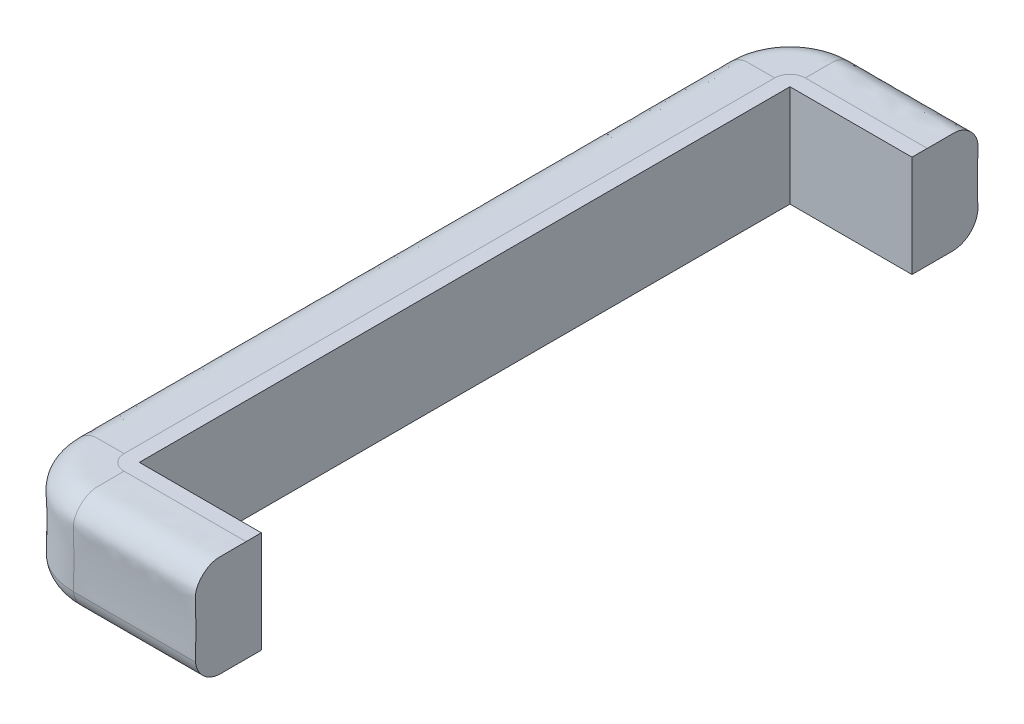
from build123d import *

# Parameters (mm, degrees)
BOSS_EXTRUDE1_DEPTH = 812.8
REVOLVE1_ANGLE      = 90
REVOLVE2_ANGLE      = 90
BOSS_EXTRUDE2_DEPTH = 152.4


with BuildPart() as part:
    # Sketch1 → Boss-Extrude1 (new body)
    with BuildSketch(Plane.XY):
        with BuildLine():
            ThreePointArc((-82.355538681, 28.241370844), (-71.973846397, 8.091370945), (-50.800000578, 0))
            ThreePointArc((-50.800000578, 0), (-28.349359902, 9.299359493), (-19.05, 31.75))
            ThreePointArc((-19.05, 31.75), (-28.349359697, 54.200640303), (-50.8, 63.5))
            ThreePointArc((-50.8, 63.5), (-71.17526234, 56.09976765), (-82.052466379, 37.348736037))
            add(Edge.make_bspline(
                [(-82.052466379, 37.348736037), (-82.090976805, 36.231888795), (-82.212926403, 33.023152502), (-82.359373775, 30.100112808), (-82.355538681, 28.241370844)],
                knots=[0.598459565, 0.598459565, 0.598459565, 0.598459565, 0.612182288, 0.638921764, 0.638921764, 0.638921764, 0.638921764], degree=3))
        make_face()
        with BuildLine():
            add(Edge.make_bspline(
                [(-19.05, 127), (-25.855154891, 127), (-39.47076115, 126.810152427), (-49.789987976, 127.000000002), (-50.800000141, 127)],
                knots=[0, 0, 0, 0, 0.126865214, 0.14096135, 0.14096135, 0.14096135, 0.14096135], degree=3))
            ThreePointArc((-50.800000141, 127), (-28.349359747, 117.700640353), (-19.05, 95.25))
            Line((-19.05, 95.25), (-19.05, 127))
        make_face()
        Polygon((-19.05, 0), (0, 0), (0, 127), (-19.05, 127), (-19.05, 95.25), (-19.05, 31.75), align=None)
        with BuildLine():
            add(Edge.make_bspline(
                [(-50.800000578, 0), (-49.628381888, -7e-09), (-38.030511338, 0.208369701), (-30.177735657, 0.179241264), (-19.05, 0)],
                knots=[0.858810349, 0.858810349, 0.858810349, 0.858810349, 0.872929316, 1, 1, 1, 1], degree=3))
            Line((-19.05, 0), (-19.05, 31.75))
            ThreePointArc((-19.05, 31.75), (-28.349359902, 9.299359493), (-50.800000578, 0))
        make_face()
        with BuildLine():
            ThreePointArc((-50.8, 63.5), (-28.349359697, 54.200640303), (-19.05, 31.75))
            Line((-19.05, 31.75), (-19.05, 95.25))
            ThreePointArc((-19.05, 95.25), (-28.349359697, 72.799359697), (-50.8, 63.5))
        make_face()
        with BuildLine():
            ThreePointArc((-50.8, 63.5), (-28.349359697, 72.799359697), (-19.05, 95.25))
            ThreePointArc((-19.05, 95.25), (-28.349359747, 117.700640353), (-50.800000141, 127))
            add(Edge.make_bspline(
                [(-50.800000141, 127), (-52.45204237, 126.999999997), (-66.792846723, 126.542873142), (-83.545544358, 110.86158671), (-82.462698948, 95.008351036), (-82.274016933, 91.123758619), (-82.270167692, 91.04392755)],
                knots=[0.14096135, 0.14096135, 0.14096135, 0.14096135, 0.164017915, 0.34847044, 0.398266482, 0.399308743, 0.399308743, 0.399308743, 0.399308743], degree=3))
            ThreePointArc((-82.270167692, 91.04392755), (-71.710759189, 71.358523483), (-50.8, 63.5))
        make_face()
        with BuildLine():
            ThreePointArc((-82.052466379, 37.348736037), (-71.17526234, 56.09976765), (-50.8, 63.5))
            ThreePointArc((-50.8, 63.5), (-71.710759189, 71.358523483), (-82.270167692, 91.04392755))
            add(Edge.make_bspline(
                [(-82.270167692, 91.04392755), (-81.534670646, 75.790138553), (-81.493584404, 53.556965039), (-82.052466379, 37.348736037)],
                knots=[0.399308743, 0.399308743, 0.399308743, 0.399308743, 0.598459565, 0.598459565, 0.598459565, 0.598459565], degree=3))
        make_face()
    extrude(amount=BOSS_EXTRUDE1_DEPTH)

    # Sketch2 → Revolve1 (revolve)
    with BuildSketch(Plane.XY.offset(812.8)):
        with BuildLine():
            Line((-19.05, 0), (0, 0))
            Line((0, 0), (0, 127))
            Line((0, 127), (-19.05, 127))
            add(Edge.make_bspline(
                [(-19.05, 127), (-25.855154891, 127), (-41.697819222, 126.77909971), (-65.875071416, 127.401952543), (-83.545544358, 110.86158671), (-81.483021396, 80.665528904), (-81.488355044, 47.485350211), (-82.359373775, 30.100112808), (-82.355538681, 28.241370844)],
                knots=[0, 0, 0, 0, 0.126865214, 0.164017915, 0.34847044, 0.398266482, 0.612182288, 0.638921764, 0.638921764, 0.638921764, 0.638921764], degree=3))
            ThreePointArc((-82.355538681, 28.241370844), (-71.973846182, 8.091370753), (-50.8, 0))
            add(Edge.make_bspline(
                [(-50.8, 0), (-49.628381507, 0), (-38.030511209, 0.2083697), (-30.177735657, 0.179241264), (-19.05, 0)],
                knots=[0.858810351, 0.858810351, 0.858810351, 0.858810351, 0.872929316, 1, 1, 1, 1], degree=3))
        make_face()
    revolve(axis=Axis((0, 0, 812.8), (0, 1, 0)), revolution_arc=REVOLVE1_ANGLE)

    # Sketch4 → Revolve2 (revolve)
    with BuildSketch(Plane(origin=(0, 0, 0), x_dir=(-1, 0, 0), z_dir=(0, 0, -1))):
        with BuildLine():
            Line((19.05, 127), (0, 127))
            Line((0, 127), (0, 0))
            Line((0, 0), (19.05, 0))
            add(Edge.make_bspline(
                [(19.05, 0), (30.177735657, 0.179241264), (38.030511209, 0.2083697), (49.628381507, 0), (50.8, 0)],
                knots=[0.858810351, 0.858810351, 0.858810351, 0.858810351, 0.985881035, 1, 1, 1, 1], degree=3))
            ThreePointArc((50.8, 0), (71.973846182, 8.091370753), (82.355538681, 28.241370844))
            add(Edge.make_bspline(
                [(82.355538681, 28.241370844), (82.359373775, 30.100112808), (81.488355044, 47.485350211), (81.483021396, 80.665528904), (83.545544358, 110.86158671), (65.875071416, 127.401952543), (41.697819222, 126.77909971), (25.855154891, 127), (19.05, 127)],
                knots=[0, 0, 0, 0, 0.026739476, 0.240655282, 0.290451324, 0.47490385, 0.51205655, 0.638921764, 0.638921764, 0.638921764, 0.638921764], degree=3))
        make_face()
    revolve(axis=Axis((0, 127, 0), (0, -1, 0)), revolution_arc=REVOLVE2_ANGLE)

    # Sketch5 → Boss-Extrude2 (add)
    with BuildSketch(Plane(origin=(0, 0, 0), x_dir=(0, 0, -1), z_dir=(1, 0, 0))):
        with BuildLine():
            Line((-812.8, 0), (-812.8, 127))
            Line((-812.8, 127), (-831.85, 127))
            add(Edge.make_bspline(
                [(-831.85, 127), (-838.655154891, 127), (-854.497819222, 126.77909971), (-878.675071416, 127.401952543), (-896.345544358, 110.86158671), (-894.283021396, 80.665528904), (-894.288355044, 47.485350211), (-895.159373775, 30.100112808), (-895.155538681, 28.241370844)],
                knots=[0, 0, 0, 0, 0.126865214, 0.164017915, 0.34847044, 0.398266482, 0.612182288, 0.638921764, 0.638921764, 0.638921764, 0.638921764], degree=3))
            ThreePointArc((-895.155538681, 28.241370844), (-884.773846182, 8.091370753), (-863.6, 0))
            add(Edge.make_bspline(
                [(-863.6, 0), (-862.428381507, 0), (-850.830511209, 0.2083697), (-842.977735657, 0.179241264), (-831.85, 0)],
                knots=[0.858810351, 0.858810351, 0.858810351, 0.858810351, 0.872929316, 1, 1, 1, 1], degree=3))
            Line((-831.85, 0), (-812.8, 0))
        make_face()
        with BuildLine():
            Line((19.05, 127), (0, 127))
            Line((0, 127), (0, 0))
            Line((0, 0), (19.05, 0))
            add(Edge.make_bspline(
                [(19.05, 0), (30.177735657, 0.179241264), (38.030511209, 0.2083697), (49.628381507, 0), (50.8, 0)],
                knots=[0.858810351, 0.858810351, 0.858810351, 0.858810351, 0.985881035, 1, 1, 1, 1], degree=3))
            ThreePointArc((50.8, 0), (71.973846182, 8.091370753), (82.355538681, 28.241370844))
            add(Edge.make_bspline(
                [(82.355538681, 28.241370844), (82.359373775, 30.100112808), (81.488355044, 47.485350211), (81.483021396, 80.665528904), (83.545544358, 110.86158671), (65.875071416, 127.401952543), (41.697819222, 126.77909971), (25.855154891, 127), (19.05, 127)],
                knots=[0, 0, 0, 0, 0.026739476, 0.240655282, 0.290451324, 0.47490385, 0.51205655, 0.638921764, 0.638921764, 0.638921764, 0.638921764], degree=3))
        make_face()
    extrude(amount=BOSS_EXTRUDE2_DEPTH)


solid = part.part
